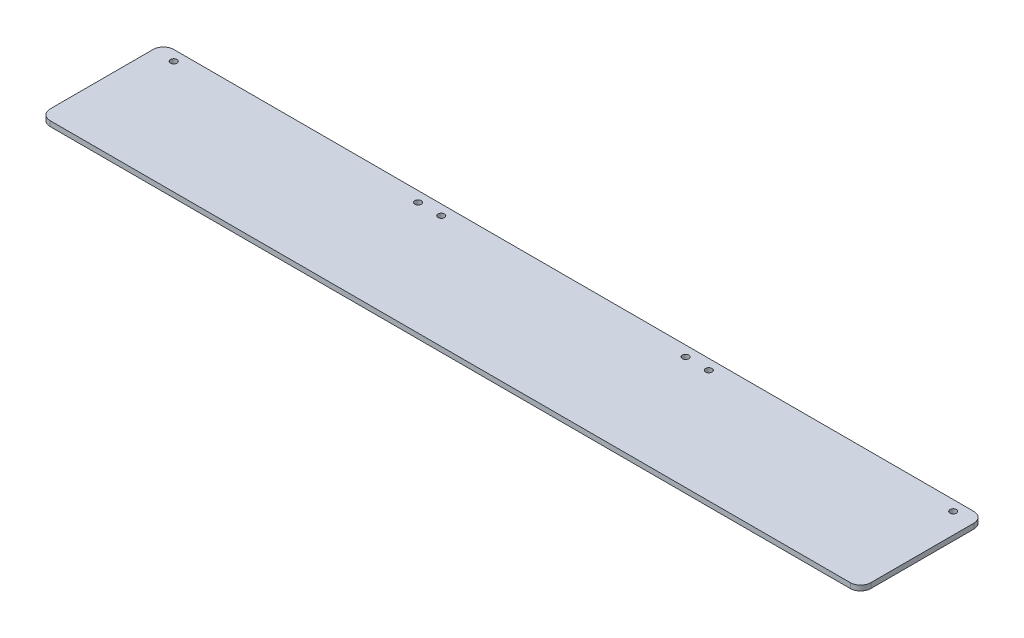
from build123d import *

# Parameters (mm, degrees)
SKETCH1_R           = 7.9375
BOSS_EXTRUDE1_DEPTH = 12.7


with BuildPart() as part:
    # Sketch1 → Boss-Extrude1 (new body)
    with BuildSketch(Plane(origin=(0, 0, 0), x_dir=(1, 0, 0), z_dir=(0, 1, 0))):
        with BuildLine():
            Line((25.4, 0), (2000.25, 0))
            ThreePointArc((2000.25, 0), (2018.210512242, 7.439487758), (2025.65, 25.4))
            Line((2025.65, 25.4), (2025.65, 279.4))
            ThreePointArc((2025.65, 279.4), (2018.210512242, 297.360512242), (2000.25, 304.8))
            Line((2000.25, 304.8), (25.4, 304.8))
            ThreePointArc((25.4, 304.8), (7.439487758, 297.360512242), (0, 279.4))
            Line((0, 279.4), (0, 25.4))
            ThreePointArc((0, 25.4), (7.439487758, 7.439487758), (25.4, 0))
        make_face()
        with Locations((50.8, 279.4)):
            Circle(SKETCH1_R, mode=Mode.SUBTRACT)
        with Locations((654.05, 279.4)):
            Circle(SKETCH1_R, mode=Mode.SUBTRACT)
        with Locations((711.2, 279.4)):
            Circle(SKETCH1_R, mode=Mode.SUBTRACT)
        with Locations((1314.45, 279.4)):
            Circle(SKETCH1_R, mode=Mode.SUBTRACT)
        with Locations((1371.6, 279.4)):
            Circle(SKETCH1_R, mode=Mode.SUBTRACT)
        with Locations((1974.85, 279.4)):
            Circle(SKETCH1_R, mode=Mode.SUBTRACT)
    extrude(amount=BOSS_EXTRUDE1_DEPTH)


solid = part.part
